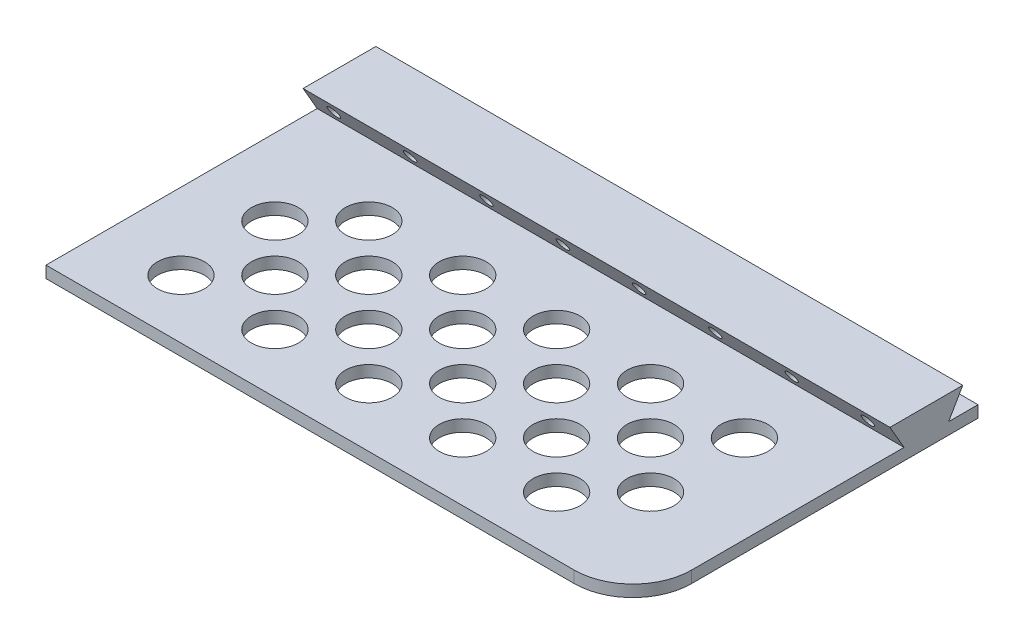
from build123d import *

# Parameters (mm, degrees)
SKETCH1_W               = 100
SKETCH1_H               = 100
BOSS_EXTRUDE1_DEPTH     = 2
BOSS_EXTRUDE2_DEPTH     = 100
FILLET1_R               = 10
SKETCH3_R               = 4
CUT_EXTRUDE1_DEPTH      = 3
LPATTERN1_COUNT         = 5
LPATTERN1_PITCH         = 16
LPATTERN1_COUNT_DIR2    = 2
LPATTERN1_PITCH_DIR2    = 16
MIRROR1_COPY_1_SKETCH_R = 4
MIRROR1_COPY_1_DEPTH    = 3
MIRROR1_COPY_2_SKETCH_R = 4
MIRROR1_COPY_2_DEPTH    = 3
MIRROR1_COPY_3_SKETCH_R = 4
MIRROR1_COPY_3_DEPTH    = 3
MIRROR1_COPY_4_SKETCH_R = 4
MIRROR1_COPY_4_DEPTH    = 3
MIRROR1_COPY_5_SKETCH_R = 4
MIRROR1_COPY_5_DEPTH    = 3
MIRROR1_COPY_6_SKETCH_R = 4
MIRROR1_COPY_6_DEPTH    = 3
MIRROR1_COPY_7_SKETCH_R = 4
MIRROR1_COPY_7_DEPTH    = 3
MIRROR1_COPY_8_SKETCH_R = 4
MIRROR1_COPY_8_DEPTH    = 3
MIRROR1_COPY_9_SKETCH_R = 4
MIRROR1_COPY_9_DEPTH    = 3
SKETCH4_W               = 41.2
SKETCH4_H               = 2
CUT_EXTRUDE2_DEPTH      = 101
SKETCH5_R               = 1
CUT_EXTRUDE3_DEPTH      = 59.8
LPATTERN2_COUNT         = 8
LPATTERN2_PITCH         = 13


with BuildPart() as part:
    # Sketch1 → Boss-Extrude1 (new body)
    with BuildSketch(Plane(origin=(0, 0, 0), x_dir=(1, 0, 0), z_dir=(0, 1, 0))):
        Rectangle(SKETCH1_W, SKETCH1_H)
    extrude(amount=BOSS_EXTRUDE1_DEPTH)

    # Sketch2 → Boss-Extrude2 (add)
    with BuildSketch(Plane(origin=(50, 0, 0), x_dir=(0, 0, -1), z_dir=(1, 0, 0))):
        Polygon((-3.8, 2), (-6.20177712, 6.16), (6.20177712, 6.16), (3.8, 2), align=None)
    extrude(amount=-BOSS_EXTRUDE2_DEPTH)

    # Fillet1
    fillet1_edges = [part.edges().sort_by_distance(p)[0] for p in [
        (50, 1, -50),
        (50, 1, 50),
    ]]
    fillet(fillet1_edges, radius=FILLET1_R)

    # Sketch3 → Cut-Extrude1 (cut, through all)
    with BuildSketch(Plane(origin=(0, 2, 0), x_dir=(1, 0, 0), z_dir=(0, 1, 0))):
        with Locations((35, -16)):
            Circle(SKETCH3_R)
        with Locations((27, -24)):
            Circle(SKETCH3_R)
    cut_extrude1 = extrude(amount=-CUT_EXTRUDE1_DEPTH, mode=Mode.SUBTRACT)

    # LPattern1: Cut-Extrude1 5 × 2
    with Locations(*[(-i * LPATTERN1_PITCH, 0, j * LPATTERN1_PITCH_DIR2) for i in range(LPATTERN1_COUNT) for j in range(LPATTERN1_COUNT_DIR2) if (i, j) != (0, 0)]):
        add(cut_extrude1, mode=Mode.SUBTRACT)

    # Mirror1: Cut-Extrude1 across plane
    add(cut_extrude1.mirror(Plane.XY), mode=Mode.SUBTRACT)

    # Mirror1 copy 1 sketch → Mirror1 copy 1 (cut, through all)
    with BuildSketch(Plane(origin=(0, 2, -16), x_dir=(1, 0, 0), z_dir=(0, 1, 0))):
        with Locations((35, 16)):
            Circle(MIRROR1_COPY_1_SKETCH_R)
        with Locations((27, 24)):
            Circle(MIRROR1_COPY_1_SKETCH_R)
    extrude(amount=-MIRROR1_COPY_1_DEPTH, mode=Mode.SUBTRACT)

    # Mirror1 copy 2 sketch → Mirror1 copy 2 (cut, through all)
    with BuildSketch(Plane(origin=(-16, 2, 0), x_dir=(1, 0, 0), z_dir=(0, 1, 0))):
        with Locations((35, 16)):
            Circle(MIRROR1_COPY_2_SKETCH_R)
        with Locations((27, 24)):
            Circle(MIRROR1_COPY_2_SKETCH_R)
    extrude(amount=-MIRROR1_COPY_2_DEPTH, mode=Mode.SUBTRACT)

    # Mirror1 copy 3 sketch → Mirror1 copy 3 (cut, through all)
    with BuildSketch(Plane(origin=(-16, 2, -16), x_dir=(1, 0, 0), z_dir=(0, 1, 0))):
        with Locations((35, 16)):
            Circle(MIRROR1_COPY_3_SKETCH_R)
        with Locations((27, 24)):
            Circle(MIRROR1_COPY_3_SKETCH_R)
    extrude(amount=-MIRROR1_COPY_3_DEPTH, mode=Mode.SUBTRACT)

    # Mirror1 copy 4 sketch → Mirror1 copy 4 (cut, through all)
    with BuildSketch(Plane(origin=(-32, 2, 0), x_dir=(1, 0, 0), z_dir=(0, 1, 0))):
        with Locations((35, 16)):
            Circle(MIRROR1_COPY_4_SKETCH_R)
        with Locations((27, 24)):
            Circle(MIRROR1_COPY_4_SKETCH_R)
    extrude(amount=-MIRROR1_COPY_4_DEPTH, mode=Mode.SUBTRACT)

    # Mirror1 copy 5 sketch → Mirror1 copy 5 (cut, through all)
    with BuildSketch(Plane(origin=(-32, 2, -16), x_dir=(1, 0, 0), z_dir=(0, 1, 0))):
        with Locations((35, 16)):
            Circle(MIRROR1_COPY_5_SKETCH_R)
        with Locations((27, 24)):
            Circle(MIRROR1_COPY_5_SKETCH_R)
    extrude(amount=-MIRROR1_COPY_5_DEPTH, mode=Mode.SUBTRACT)

    # Mirror1 copy 6 sketch → Mirror1 copy 6 (cut, through all)
    with BuildSketch(Plane(origin=(-48, 2, 0), x_dir=(1, 0, 0), z_dir=(0, 1, 0))):
        with Locations((35, 16)):
            Circle(MIRROR1_COPY_6_SKETCH_R)
        with Locations((27, 24)):
            Circle(MIRROR1_COPY_6_SKETCH_R)
    extrude(amount=-MIRROR1_COPY_6_DEPTH, mode=Mode.SUBTRACT)

    # Mirror1 copy 7 sketch → Mirror1 copy 7 (cut, through all)
    with BuildSketch(Plane(origin=(-48, 2, -16), x_dir=(1, 0, 0), z_dir=(0, 1, 0))):
        with Locations((35, 16)):
            Circle(MIRROR1_COPY_7_SKETCH_R)
        with Locations((27, 24)):
            Circle(MIRROR1_COPY_7_SKETCH_R)
    extrude(amount=-MIRROR1_COPY_7_DEPTH, mode=Mode.SUBTRACT)

    # Mirror1 copy 8 sketch → Mirror1 copy 8 (cut, through all)
    with BuildSketch(Plane(origin=(-64, 2, 0), x_dir=(1, 0, 0), z_dir=(0, 1, 0))):
        with Locations((35, 16)):
            Circle(MIRROR1_COPY_8_SKETCH_R)
        with Locations((27, 24)):
            Circle(MIRROR1_COPY_8_SKETCH_R)
    extrude(amount=-MIRROR1_COPY_8_DEPTH, mode=Mode.SUBTRACT)

    # Mirror1 copy 9 sketch → Mirror1 copy 9 (cut, through all)
    with BuildSketch(Plane(origin=(-64, 2, -16), x_dir=(1, 0, 0), z_dir=(0, 1, 0))):
        with Locations((35, 16)):
            Circle(MIRROR1_COPY_9_SKETCH_R)
        with Locations((27, 24)):
            Circle(MIRROR1_COPY_9_SKETCH_R)
    extrude(amount=-MIRROR1_COPY_9_DEPTH, mode=Mode.SUBTRACT)

    # Sketch4 → Cut-Extrude2 (cut, through all)
    with BuildSketch(Plane.ZY.offset(50)):
        with Locations((-29.4, 1)):
            Rectangle(SKETCH4_W, SKETCH4_H)
    extrude(amount=-CUT_EXTRUDE2_DEPTH, mode=Mode.SUBTRACT)

    # Sketch5 → Cut-Extrude3 (cut, through all)
    with BuildSketch(Plane.XY.offset(50)):
        with Locations((-46, 4)):
            Circle(SKETCH5_R)
    cut_extrude3 = extrude(amount=-CUT_EXTRUDE3_DEPTH, mode=Mode.SUBTRACT)

    # LPattern2: Cut-Extrude3 ×8
    with Locations(*[(i * LPATTERN2_PITCH, 0, 0) for i in range(1, LPATTERN2_COUNT)]):
        add(cut_extrude3, mode=Mode.SUBTRACT)


solid = part.part
